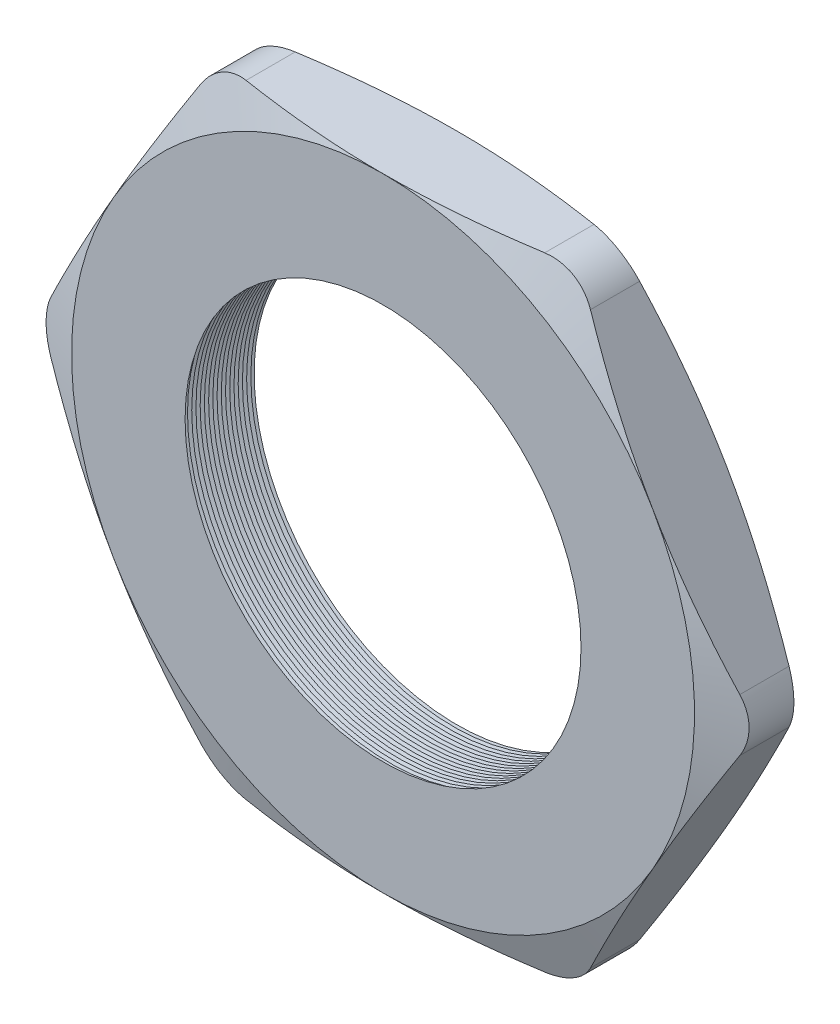
from build123d import *

# Parameters (mm, degrees)
SKETCH1_R          = 9.525
EXTRUDE1_DEPTH     = 3.556
FILLET1_R          = 2.54
SKETCH2_OUTSIDE_W  = 69.924
SKETCH2_OUTSIDE_H  = 66.074
SKETCH2_OUTSIDE_R  = 14.986
CUT_EXTRUDE1_DEPTH = 4.556
CUT_EXTRUDE1_DRAFT = -70
SKETCH3_OUTSIDE_W  = 69.924
SKETCH3_OUTSIDE_H  = 66.074
SKETCH3_OUTSIDE_R  = 14.986
CUT_EXTRUDE2_DEPTH = 4.5560001
CUT_EXTRUDE2_DRAFT = -70
LPATTERN1_COUNT    = 18
LPATTERN1_PITCH    = 0.2032


with BuildPart() as part:
    # Sketch1 → Extrude1 (new body)
    with BuildSketch(Plane.XY):
        Polygon((-17.304342268, 0), (-8.652171134, -14.986), (8.652171134, -14.986), (17.304342268, 0), (8.652171134, 14.986), (-8.652171134, 14.986), align=None)
        Circle(SKETCH1_R, mode=Mode.SUBTRACT)
    extrude(amount=EXTRUDE1_DEPTH)

    # Fillet1
    fillet1_edges = [part.edges().sort_by_distance(p)[0] for p in [
        (-8.652171134, 14.986, 1.778),
        (8.652171134, 14.986, 1.778),
        (17.304342268, 0, 1.778),
        (8.652171134, -14.986, 1.778),
        (-8.652171134, -14.986, 1.778),
        (-17.304342268, 0, 1.778),
    ]]
    fillet(fillet1_edges, radius=FILLET1_R)


with BuildPart() as cut_extrude1_tool:
    # Sketch2 outside → Cut-Extrude1 (with draft: the straight prism first)
    with BuildSketch(Plane.XY.offset(3.556)):
        Rectangle(SKETCH2_OUTSIDE_W, SKETCH2_OUTSIDE_H)
        Circle(SKETCH2_OUTSIDE_R, mode=Mode.SUBTRACT)
    extrude(amount=-CUT_EXTRUDE1_DEPTH)
    # Cut-Extrude1: the draft: its side faces are tilted about the plane it starts from
    cut_extrude1_sides = [cut_extrude1_tool.faces().sort_by_distance(p)[0] for p in [
        (0, -33.037, 1.278),
        (34.962, 0, 1.278),
        (0, 33.037, 1.278),
        (-34.962, 0, 1.278),
        (-14.986, 0, 1.278),
    ]]
    draft(cut_extrude1_sides, Plane.XY.offset(3.556), CUT_EXTRUDE1_DRAFT)


with BuildPart() as part_1:
    add(part.part)

    # Cut-Extrude1: cut by cut_extrude1_tool
    add(cut_extrude1_tool.part, mode=Mode.SUBTRACT)


with BuildPart() as cut_extrude2_tool:
    # Sketch3 outside → Cut-Extrude2 (with draft: the straight prism first)
    with BuildSketch(Plane(origin=(0, 0, 0), x_dir=(-1, 0, 0), z_dir=(0, 0, -1))):
        Rectangle(SKETCH3_OUTSIDE_W, SKETCH3_OUTSIDE_H)
        Circle(SKETCH3_OUTSIDE_R, mode=Mode.SUBTRACT)
    extrude(amount=-CUT_EXTRUDE2_DEPTH)
    # Cut-Extrude2: the draft: its side faces are tilted about the plane it starts from
    cut_extrude2_sides = [cut_extrude2_tool.faces().sort_by_distance(p)[0] for p in [
        (0, -33.037, 2.27800005),
        (-34.962, 0, 2.27800005),
        (0, 33.037, 2.27800005),
        (34.962, 0, 2.27800005),
        (14.986, 0, 2.27800005),
    ]]
    draft(cut_extrude2_sides, Plane(origin=(0, 0, 0), x_dir=(-1, 0, 0), z_dir=(0, 0, -1)), CUT_EXTRUDE2_DRAFT)


with BuildPart() as part_2:
    add(part_1.part)

    # Cut-Extrude2: cut by cut_extrude2_tool
    add(cut_extrude2_tool.part, mode=Mode.SUBTRACT)

    # Sketch4 → Cut-Revolve1 (revolve, cut)
    with BuildSketch(Plane(origin=(0, 0, 0), x_dir=(1, 0, 0), z_dir=(0, 1, 0))):
        Polygon((-9.525, -3.556), (-9.525, -3.116059095), (-9.906, -3.336029547), align=None)
    cut_revolve1 = revolve(axis=Axis((0, 0, 3.556), (0, 0, -1)), mode=Mode.SUBTRACT)

    # LPattern1: Cut-Revolve1 ×18
    with Locations(*[(0, 0, -i * LPATTERN1_PITCH) for i in range(1, LPATTERN1_COUNT)]):
        add(cut_revolve1, mode=Mode.SUBTRACT)


solid = part_2.part
